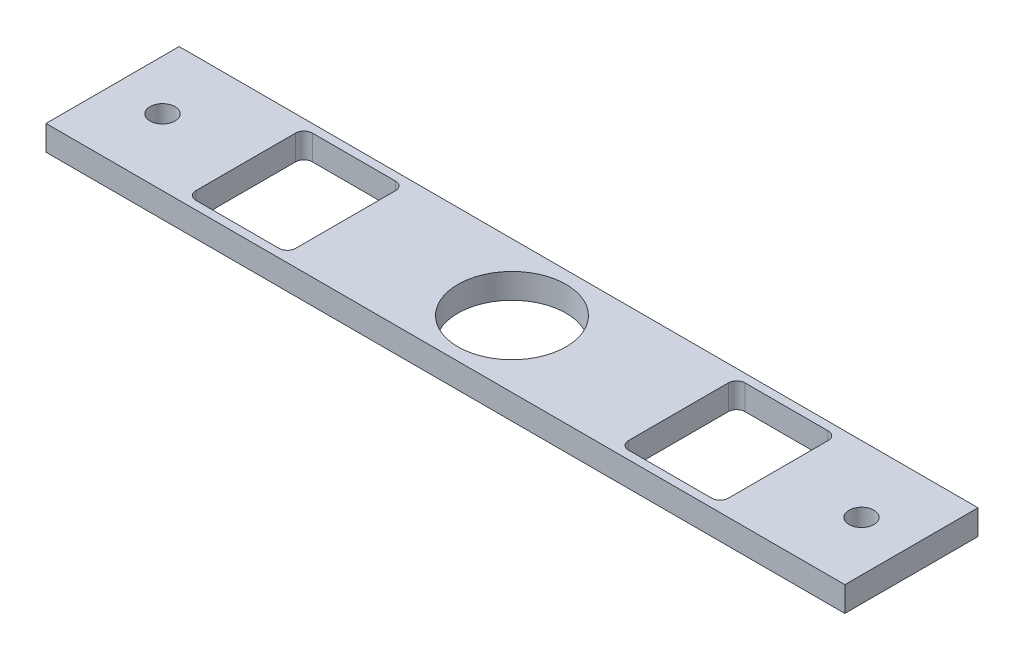
from build123d import *

# Parameters (mm, degrees)
SKETCH1_W           = 304.8
SKETCH1_H           = 50.8
BOSS_EXTRUDE1_DEPTH = 9.525
SKETCH2_R           = 20.6375
CUT_EXTRUDE1_DEPTH  = 10.525
SKETCH3_R           = 4.7625
CUT_EXTRUDE2_DEPTH  = 10.525
SKETCH4_W           = 38.1
SKETCH4_H           = 44.45
CUT_EXTRUDE3_DEPTH  = 10.525
SKETCH5_R           = 4.7625
CUT_EXTRUDE4_DEPTH  = 10.525
FILLET1_R           = 3.175


with BuildPart() as part:
    # Sketch1 → Boss-Extrude1 (new body)
    with BuildSketch(Plane(origin=(0, 0, 0), x_dir=(1, 0, 0), z_dir=(0, 1, 0))):
        Rectangle(SKETCH1_W, SKETCH1_H)
    extrude(amount=BOSS_EXTRUDE1_DEPTH)

    # Sketch2 → Cut-Extrude1 (cut, through all)
    with BuildSketch(Plane(origin=(0, 9.525, 0), x_dir=(1, 0, 0), z_dir=(0, 1, 0))):
        with Locations(Location((0, 0, 0), (0, 0, 270))):  # turned: the seam where the file's is
            Circle(SKETCH2_R)
    extrude(amount=-CUT_EXTRUDE1_DEPTH, mode=Mode.SUBTRACT)

    # Sketch3 → Cut-Extrude2 (cut, through all)
    with BuildSketch(Plane(origin=(0, 9.525, 0), x_dir=(1, 0, 0), z_dir=(0, 1, 0))):
        with Locations(Location((133.35, 0, 0), (0, 0, 270))):  # turned: the seam where the file's is
            Circle(SKETCH3_R)
    extrude(amount=-CUT_EXTRUDE2_DEPTH, mode=Mode.SUBTRACT)

    # Sketch4 → Cut-Extrude3 (cut, through all)
    with BuildSketch(Plane(origin=(0, 9.525, 0), x_dir=(1, 0, 0), z_dir=(0, 1, 0))):
        with Locations((-82.55, 0)):
            Rectangle(SKETCH4_W, SKETCH4_H)
        with Locations((82.55, 0)):
            Rectangle(SKETCH4_W, SKETCH4_H)
    extrude(amount=-CUT_EXTRUDE3_DEPTH, mode=Mode.SUBTRACT)

    # Sketch5 → Cut-Extrude4 (cut, through all)
    with BuildSketch(Plane(origin=(0, 9.525, 0), x_dir=(1, 0, 0), z_dir=(0, 1, 0))):
        with Locations(Location((-133.35, 0, 0), (0, 0, 270))):  # turned: the seam where the file's is
            Circle(SKETCH5_R)
    extrude(amount=-CUT_EXTRUDE4_DEPTH, mode=Mode.SUBTRACT)

    # Fillet1
    fillet1_edges = [part.edges().sort_by_distance(p)[0] for p in [
        (-63.5, 4.7625, -22.225),
        (-63.5, 4.7625, 22.225),
        (-101.6, 4.7625, 22.225),
        (-101.6, 4.7625, -22.225),
        (101.6, 4.7625, -22.225),
        (101.6, 4.7625, 22.225),
        (63.5, 4.7625, 22.225),
        (63.5, 4.7625, -22.225),
    ]]
    fillet(fillet1_edges, radius=FILLET1_R)


solid = part.part
